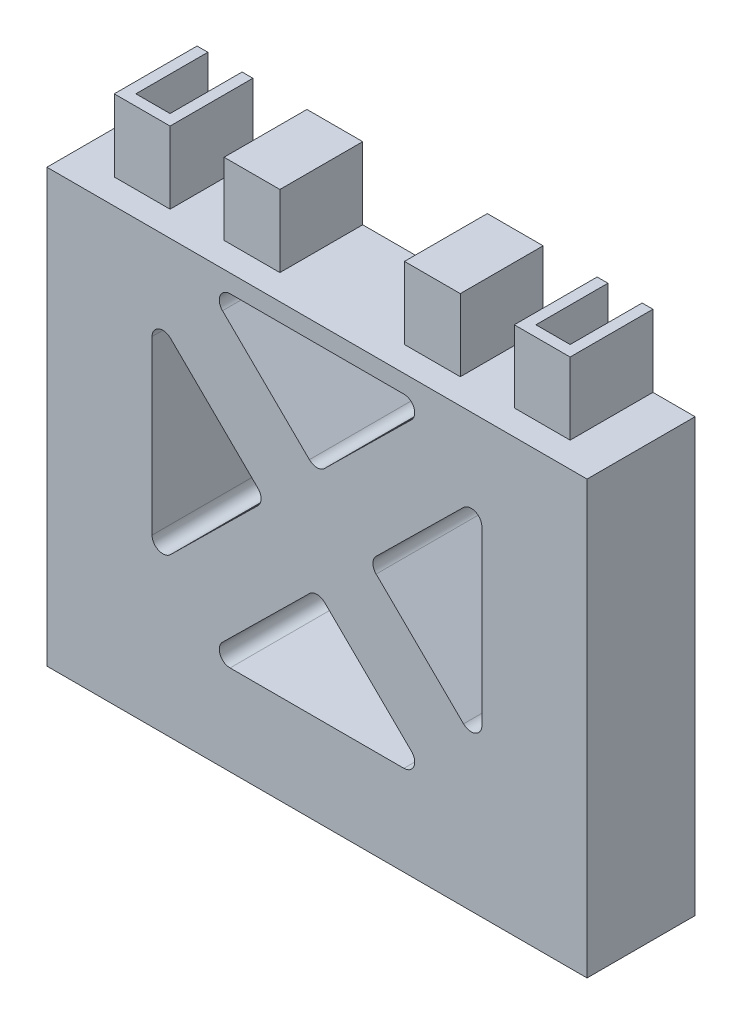
from build123d import *

# Parameters (mm, degrees)
BOSS_EXTRUDE1_DEPTH        = 120
BOSS_EXTRUDE2_DEPTH        = 20
CUT_EXTRUDE1_DEPTH         = 20
SKETCH17_W                 = 82.2
SKETCH17_H                 = 120
BOSS_EXTRUDE3_DEPTH        = 20
SKETCH18_W                 = 15.5
SKETCH18_H                 = 23
CUT_EXTRUDE2_DEPTH         = 20
SKETCH19_W                 = 15.5
SKETCH19_H                 = 23
BOSS_EXTRUDE4_DEPTH        = 20
CUT_EXTRUDE3_DEPTH         = 37
FILLET3_R                  = 3
SKETCH22_W                 = 30
SKETCH22_H                 = 120
BOSS_EXTRUDE5_DEPTH        = 5
SKETCH23_W                 = 30
SKETCH23_H                 = 120
BOSS_EXTRUDE6_DEPTH        = 5
F_8_CLEARANCE_HOLE1_REACH  = 187.624
F_8_CLEARANCE_HOLE1_BORE_R = 2.2479


with BuildPart() as part:
    # Sketch1 → Boss-Extrude1 (new body)
    with BuildSketch(Plane(origin=(0, 0, 0), x_dir=(1, 0, 0), z_dir=(0, 1, 0))):
        Polygon((-70, 15), (-70, -15), (70, -15), (70, 15), (60.3, 15), (60.3, -5), (50.8, -5), (50.8, 15), (41.1, 15), (41.1, -5), (-41.1, -5), (-41.1, 15), (-50.8, 15), (-50.8, -5), (-60.3, -5), (-60.3, 15), align=None)
    extrude(amount=BOSS_EXTRUDE1_DEPTH)

    # Sketch2 → Boss-Extrude2 (add)
    with BuildSketch(Plane(origin=(0, 120, 0), x_dir=(1, 0, 0), z_dir=(0, 1, 0))):
        Polygon((-63.3, -8), (-63.3, 15), (-60.3, 15), (-60.3, -5), (-50.8, -5), (-50.8, 15), (-47.8, 15), (-47.8, -8), align=None)
        Polygon((63.3, -8), (63.3, 15), (60.3, 15), (60.3, -5), (50.8, -5), (50.8, 15), (47.8, 15), (47.8, -8), align=None)
    extrude(amount=BOSS_EXTRUDE2_DEPTH)

    # Sketch3 → Cut-Extrude1 (cut)
    with BuildSketch(Plane.XZ):
        Polygon((-47.8, 8), (-47.8, -15), (-50.8, -15), (-50.8, 5), (-60.3, 5), (-60.3, -15), (-63.3, -15), (-63.3, 8), align=None)
        Polygon((63.3, 8), (63.3, -15), (60.3, -15), (60.3, 5), (50.8, 5), (50.8, -15), (47.8, -15), (47.8, 8), align=None)
    extrude(amount=-CUT_EXTRUDE1_DEPTH, mode=Mode.SUBTRACT)

    # Sketch17 → Boss-Extrude3 (add)
    with BuildSketch(Plane(origin=(0, 0, 5), x_dir=(-1, 0, 0), z_dir=(0, 0, -1))):
        with Locations((0, 60)):
            Rectangle(SKETCH17_W, SKETCH17_H)
    extrude(amount=BOSS_EXTRUDE3_DEPTH)

    # Sketch18 → Cut-Extrude2 (cut)
    with BuildSketch(Plane.XZ):
        with Locations((-25.05, -3.5)):
            Rectangle(SKETCH18_W, SKETCH18_H)
        with Locations((25.05, -3.5)):
            Rectangle(SKETCH18_W, SKETCH18_H)
    extrude(amount=-CUT_EXTRUDE2_DEPTH, mode=Mode.SUBTRACT)

    # Sketch19 → Boss-Extrude4 (add)
    with BuildSketch(Plane(origin=(0, 120, 0), x_dir=(1, 0, 0), z_dir=(0, 1, 0))):
        with Locations((-25.05, 3.5)):
            Rectangle(SKETCH19_W, SKETCH19_H)
        with Locations((25.05, 3.5)):
            Rectangle(SKETCH19_W, SKETCH19_H)
    extrude(amount=BOSS_EXTRUDE4_DEPTH)

    # Sketch20 → Cut-Extrude3 (cut)
    with BuildSketch(Plane(origin=(0, 0, -15), x_dir=(-1, 0, 0), z_dir=(0, 0, -1))):
        Polygon((0, 25), (31.464278342, 25), (0, 55.968777895), (-31.464278342, 25), align=None)
        Polygon((45.8, 70), (45.8, 101.047518053), (14.255721658, 70), (45.8, 38.952481947), align=None)
        Polygon((0, 115), (-31.464278342, 115), (0, 84.031222105), (31.464278342, 115), align=None)
        Polygon((-45.8, 70), (-45.8, 101.047518053), (-14.255721658, 70), (-45.8, 38.952481947), align=None)
    extrude(amount=-CUT_EXTRUDE3_DEPTH, mode=Mode.SUBTRACT)

    # Fillet3
    fillet3_edges = [part.edges().sort_by_distance(p)[0] for p in [
        (-31.464278342, 115, 0),
        (0, 84.031222105, 0),
        (31.464278342, 115, 0),
        (-45.8, 38.952481947, 0),
        (-14.255721658, 70, 0),
        (-45.8, 101.047518053, 0),
        (45.8, 38.952481947, 0),
        (45.8, 101.047518053, 0),
        (14.255721658, 70, 0),
        (31.464278342, 25, 0),
        (0, 55.968777895, 0),
        (-31.464278342, 25, 0),
    ]]
    fillet(fillet3_edges, radius=FILLET3_R)

    # Sketch22 → Boss-Extrude5 (add)
    with BuildSketch(Plane(origin=(70, 0, 0), x_dir=(0, 0, -1), z_dir=(1, 0, 0))):
        with Locations((0, 60)):
            Rectangle(SKETCH22_W, SKETCH22_H)
    extrude(amount=BOSS_EXTRUDE5_DEPTH)

    # Sketch23 → Boss-Extrude6 (add)
    with BuildSketch(Plane.ZY.offset(70)):
        with Locations((0, 60)):
            Rectangle(SKETCH23_W, SKETCH23_H)
    extrude(amount=BOSS_EXTRUDE6_DEPTH)

    # #8 Clearance Hole1 bore (on position points) → #8 Clearance Hole1 (cut, up to next)
    with BuildSketch(Plane(origin=(-75, 107.5, -5), x_dir=(0, 0, -1), z_dir=(-1, 0, 0)), mode=Mode.PRIVATE) as f_8_clearance_hole1_sk1:
        Circle(F_8_CLEARANCE_HOLE1_BORE_R)
    f_8_clearance_hole1_tool1 = extrude(f_8_clearance_hole1_sk1.sketch, amount=-F_8_CLEARANCE_HOLE1_REACH, mode=Mode.PRIVATE) & part.part
    # #8 Clearance Hole1 bore (on position points) → #8 Clearance Hole1 (cut, up to next)
    with BuildSketch(Plane(origin=(-75, 107.5, -5), x_dir=(0, 0, -1), z_dir=(-1, 0, 0)), mode=Mode.PRIVATE) as f_8_clearance_hole1_sk2:
        with Locations((0, 75)):
            Circle(F_8_CLEARANCE_HOLE1_BORE_R)
    f_8_clearance_hole1_tool2 = extrude(f_8_clearance_hole1_sk2.sketch, amount=-F_8_CLEARANCE_HOLE1_REACH, mode=Mode.PRIVATE) & part.part
    add(f_8_clearance_hole1_tool1.solids().sort_by_distance((-75, 107.5, -5))[0], mode=Mode.SUBTRACT)
    add(f_8_clearance_hole1_tool2.solids().sort_by_distance((-75, 32.5, -5))[0], mode=Mode.SUBTRACT)


solid = part.part
